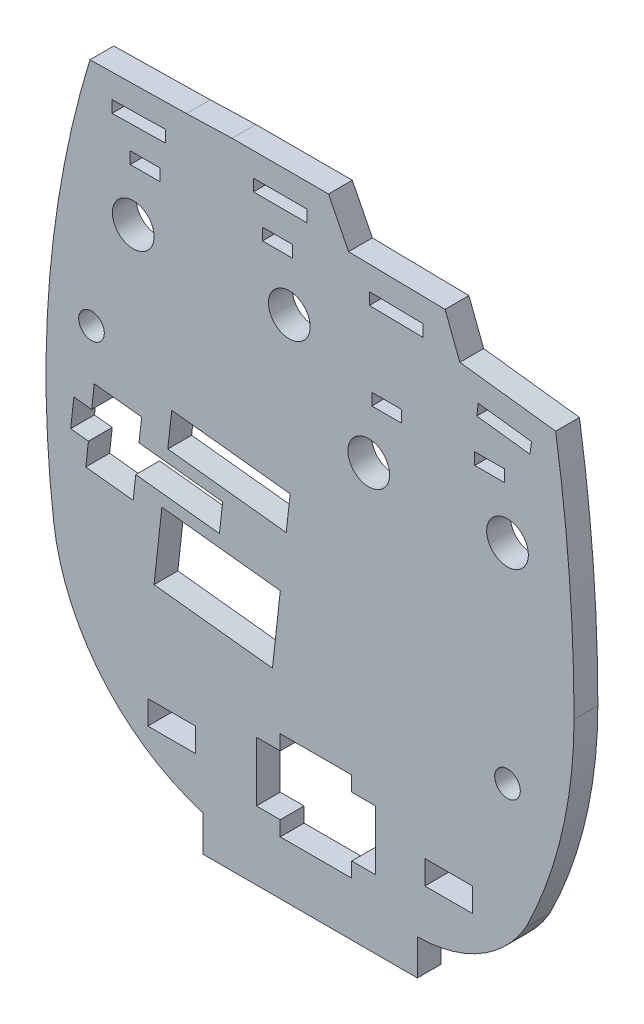
from build123d import *

# Parameters (mm, degrees)
SKETCH1_R           = 2.15
SKETCH1_R_2         = 3.5
SKETCH1_W           = 9.000072
SKETCH1_H           = 2
SKETCH1_W_2         = 5
BOSS_EXTRUDE1_DEPTH = 4
SKETCH2_W           = 8
SKETCH2_H           = 4
CUT_EXTRUDE1_DEPTH  = 5


with BuildPart() as part:
    # Sketch1 → Boss-Extrude1 (new body)
    with BuildSketch(Plane.XY):
        with BuildLine():
            Line((-12.978640908, -18), (-12.978640908, -24))
            Line((-12.978640908, -24), (23.021359092, -24))
            Line((23.021359092, -24), (23.021359092, -18))
            ThreePointArc((23.021359092, -18), (33.536808213, -15.187172163), (41.243562055, -7.5))
            ThreePointArc((41.243562055, -7.5), (47.269076761, 9.160930487), (49.313899811, 26.759570515))
            ThreePointArc((49.313899811, 26.759570515), (48.54170687, 46.985091914), (46.229623828, 67.092858318))
            Line((46.229623828, 67.092858318), (30.150376172, 69.067141682))
            Line((30.150376172, 69.067141682), (27.668766331, 75.523635508))
            Line((27.668766331, 75.523635508), (11.471233669, 75.806364492))
            Line((11.471233669, 75.806364492), (8.1, 82.51))
            Line((8.1, 82.51), (-8.1, 82.51))
            Line((-8.1, 82.51), (-15.746217975, 82.280462515))
            Line((-15.746217975, 82.280462515), (-31.943782025, 81.999537485))
            ThreePointArc((-31.943782025, 81.999537485), (-38.683922922, 47.231229605), (-38.032696315, 11.821617405))
            ThreePointArc((-38.032696315, 11.821617405), (-29.918009554, -6.796134249), (-12.978640908, -18))
        make_face()
        with Locations((38.147341743, 11.821617405)):
            Circle(SKETCH1_R, mode=Mode.SUBTRACT)
        with Locations((-24.678960076, 61.651218734)):
            Circle(SKETCH1_R_2, mode=Mode.SUBTRACT)
        with Locations((1.521420673, 61.651218734)):
            Circle(SKETCH1_R_2, mode=Mode.SUBTRACT)
        with Locations((14.86306514, 46.821617405)):
            Circle(SKETCH1_R_2, mode=Mode.SUBTRACT)
        with Locations((38.147341743, 46.821617405)):
            Circle(SKETCH1_R_2, mode=Mode.SUBTRACT)
        with Locations((-31.681501662, 43.456405989)):
            Circle(SKETCH1_R, mode=Mode.SUBTRACT)
        with Locations((0, 77.51)):
            Rectangle(SKETCH1_W, SKETCH1_H, mode=Mode.SUBTRACT)
        Polygon((-4, -2.5), (0, -2.5), (0, 0), (12, 0), (12, -2.5), (16, -2.5), (16, -12.5), (12, -12.5), (12, -15), (0, -15), (0, -12.5), (-4, -12.5), align=None, mode=Mode.SUBTRACT)
        with Locations((35.147341743, 56.321617405)):
            Rectangle(SKETCH1_W_2, SKETCH1_H, mode=Mode.SUBTRACT)
        Polygon((-28.274995137, 78.062566115), (-19.276276454, 78.218636824), (-19.241594351, 76.218937559), (-28.240313034, 76.062866849), align=None, mode=Mode.SUBTRACT)
        with Locations((17.86306514, 56.321617405)):
            Rectangle(SKETCH1_W_2, SKETCH1_H, mode=Mode.SUBTRACT)
        with Locations((-0.478579327, 71.151218734)):
            Rectangle(SKETCH1_W_2, SKETCH1_H, mode=Mode.SUBTRACT)
        Polygon((15.000839752, 71.744145677), (14.965934939, 69.744450286), (23.964636184, 69.587377372), (23.999540997, 71.587072762), align=None, mode=Mode.SUBTRACT)
        Polygon((42.16901604, 63.561398961), (33.236029212, 64.658231826), (32.992290526, 62.673139523), (41.925277354, 61.576306658), align=None, mode=Mode.SUBTRACT)
        Polygon((1.667459367, 35.705611754), (1.005748572, 29.742211816), (-18.872251222, 31.947914464), (-18.210540428, 37.911314402), align=None, mode=Mode.SUBTRACT)
        with Locations((-22.678960076, 71.151218734)):
            Rectangle(SKETCH1_W_2, SKETCH1_H, mode=Mode.SUBTRACT)
        Polygon((0.013182381, 20.797111909), (-1.310239208, 8.870312032), (-21.188239002, 11.076014679), (-19.864817414, 23.002814556), align=None, mode=Mode.SUBTRACT)
        Polygon((-10.203, 23.988271038), (-9.6615, 28.868319988), (-23.705306855, 30.426648908), (-23.264166325, 34.402248867), (-31.215366243, 35.284529926), (-31.656506773, 31.308929968), (-34.636711633, 31.639619464), (-35.178211633, 26.759570515), (-32.198006773, 26.428881018), (-32.639147302, 22.453281059), (-24.687947384, 21.571), (-24.246806855, 25.546599959), align=None, mode=Mode.SUBTRACT)
    extrude(amount=BOSS_EXTRUDE1_DEPTH)

    # Sketch2 → Cut-Extrude1 (cut, through all)
    with BuildSketch(Plane(origin=(0, 0, 0), x_dir=(-1, 0, 0), z_dir=(0, 0, -1))):
        with Locations((-28.271359092, -8)):
            Rectangle(SKETCH2_W, SKETCH2_H)
        with Locations((18.228640908, -8)):
            Rectangle(SKETCH2_W, SKETCH2_H)
    extrude(amount=-CUT_EXTRUDE1_DEPTH, mode=Mode.SUBTRACT)


solid = part.part
